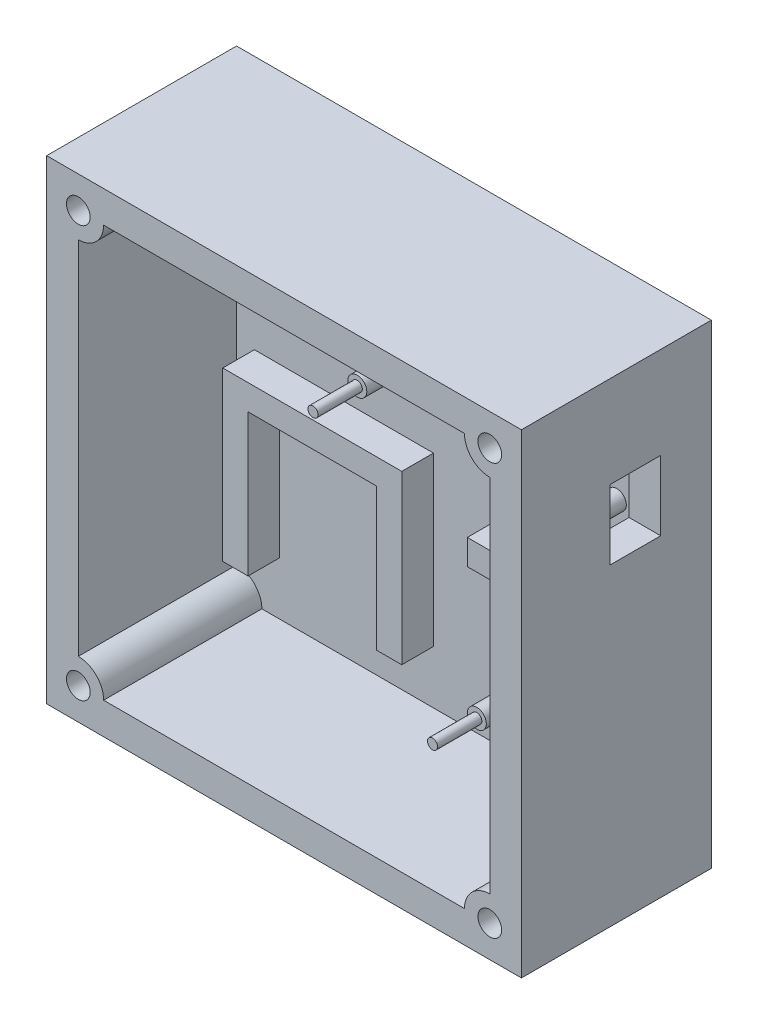
from build123d import *

# Parameters (mm, degrees)
SKETCH1_W           = 95.25
SKETCH1_H           = 95.25
BOSS_EXTRUDE1_DEPTH = 38.1
SHELL1_T            = -6.35
BOSS_EXTRUDE2_DEPTH = 31.75
SKETCH3_R           = 1.905
SKETCH3_R_2         = 1.016
BOSS_EXTRUDE3_DEPTH = 6.35
SKETCH4_R           = 1.016
BOSS_EXTRUDE4_DEPTH = 8.89
SKETCH5_R           = 1.905
SKETCH5_W           = 24.1935
SKETCH5_H           = 5.08
BOSS_EXTRUDE5_DEPTH = 6.35
SKETCH7_R           = 1.016
BOSS_EXTRUDE6_DEPTH = 8.89
SKETCH8_R           = 2.38125
CUT_EXTRUDE1_DEPTH  = 8.89
BOSS_EXTRUDE7_DEPTH = 6.35
SKETCH12_W          = 10.16
SKETCH12_H          = 13.97
CUT_EXTRUDE2_DEPTH  = 6.35


with BuildPart() as part:
    # Sketch1 → Boss-Extrude1 (new body)
    with BuildSketch(Plane.XY):
        Rectangle(SKETCH1_W, SKETCH1_H)
    extrude(amount=BOSS_EXTRUDE1_DEPTH)

    # Shell1
    shell1_openings = [part.faces().sort_by_distance(p)[0] for p in [
        (0, 0, 38.1),
    ]]
    offset(amount=SHELL1_T, openings=shell1_openings, kind=Kind.INTERSECTION)

    # Sketch2 → Boss-Extrude2 (add)
    with BuildSketch(Plane.XY.offset(38.1)):
        with BuildLine():
            Line((-41.275, 41.275), (-36.195, 41.275))
            ThreePointArc((-36.195, 41.275), (-37.682897552, 37.682897552), (-41.275, 36.195))
            Line((-41.275, 36.195), (-41.275, 41.275))
        make_face()
        with BuildLine():
            Line((36.195, 41.275), (41.275, 41.275))
            Line((41.275, 41.275), (41.275, 36.195))
            ThreePointArc((41.275, 36.195), (37.682897552, 37.682897552), (36.195, 41.275))
        make_face()
        with BuildLine():
            Line((41.275, -36.195), (41.275, -41.275))
            Line((41.275, -41.275), (36.195, -41.275))
            ThreePointArc((36.195, -41.275), (37.682897552, -37.682897552), (41.275, -36.195))
        make_face()
        with BuildLine():
            Line((-41.275, -36.195), (-41.275, -41.275))
            Line((-41.275, -41.275), (-36.195, -41.275))
            ThreePointArc((-36.195, -41.275), (-37.682897552, -37.682897552), (-41.275, -36.195))
        make_face()
    extrude(amount=-BOSS_EXTRUDE2_DEPTH)

    # Sketch3 → Boss-Extrude3 (add)
    with BuildSketch(Plane.XY.offset(6.35)):
        with Locations((35.015710728, 31.115)):
            Circle(SKETCH3_R)
        with Locations((-10.704289272, 31.115)):
            Circle(SKETCH3_R_2)
        with Locations((-10.704289272, 13.335)):
            Circle(SKETCH3_R)
        with Locations((35.015710728, 13.335)):
            Circle(SKETCH3_R)
    extrude(amount=BOSS_EXTRUDE3_DEPTH)

    # Sketch4 → Boss-Extrude4 (add)
    with BuildSketch(Plane.XY.offset(12.7)):
        with Locations((-10.704289272, 31.115)):
            Circle(SKETCH4_R)
        with Locations((-10.704289272, 13.335)):
            Circle(SKETCH4_R)
        with Locations((35.015710728, 31.115)):
            Circle(SKETCH4_R)
        with Locations((35.015710728, 13.335)):
            Circle(SKETCH4_R)
    extrude(amount=BOSS_EXTRUDE4_DEPTH)

    # Sketch5 → Boss-Extrude5 (add)
    with BuildSketch(Plane.XY.offset(6.35)):
        with Locations((13.2715, -32.385)):
            Circle(SKETCH5_R)
        with Locations((33.655, -32.385)):
            Circle(SKETCH5_R)
        with Locations((23.46325, -4.445)):
            Rectangle(SKETCH5_W, SKETCH5_H)
    extrude(amount=BOSS_EXTRUDE5_DEPTH)

    # Sketch7 → Boss-Extrude6 (add)
    with BuildSketch(Plane.XY.offset(12.7)):
        with Locations((13.2715, -32.385)):
            Circle(SKETCH7_R)
        with Locations((33.655, -32.385)):
            Circle(SKETCH7_R)
    extrude(amount=BOSS_EXTRUDE6_DEPTH)

    # Sketch8 → Cut-Extrude1 (cut)
    with BuildSketch(Plane.XY.offset(38.1)):
        with Locations((-41.275, 41.275)):
            Circle(SKETCH8_R)
        with Locations((41.275, 41.275)):
            Circle(SKETCH8_R)
        with Locations((41.275, -41.275)):
            Circle(SKETCH8_R)
        with Locations((-41.275, -41.275)):
            Circle(SKETCH8_R)
    extrude(amount=-CUT_EXTRUDE1_DEPTH, mode=Mode.SUBTRACT)

    # Sketch10 → Boss-Extrude7 (add)
    with BuildSketch(Plane.XY.offset(6.35)):
        Polygon((-37.696932409, -30.607), (-37.696932409, 2.9972), (-1.781332409, 2.9972), (-1.781332409, -30.607), (-6.861332409, -30.607), (-6.861332409, -2.0828), (-32.616932409, -2.0828), (-32.616932409, -30.607), align=None)
    extrude(amount=BOSS_EXTRUDE7_DEPTH)

    # Sketch12 → Cut-Extrude2 (cut)
    with BuildSketch(Plane(origin=(47.625, 0, 0), x_dir=(0, 0, -1), z_dir=(1, 0, 0))):
        with Locations((-15.24, 22.225)):
            Rectangle(SKETCH12_W, SKETCH12_H)
    extrude(amount=-CUT_EXTRUDE2_DEPTH, mode=Mode.SUBTRACT)


solid = part.part
